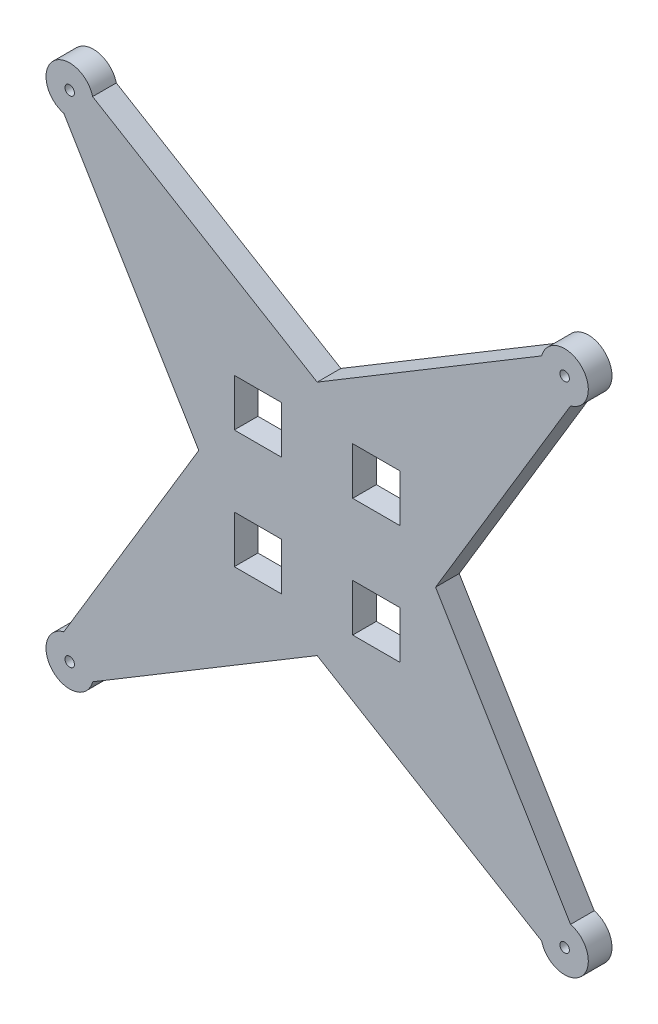
from build123d import *

# Parameters (mm, degrees)
ESBO_O1_R                = 2
ESBO_O1_W                = 20
ESBO_O1_H                = 20
RESSALTO_EXTRUS_O1_DEPTH = 10
ESBO_O3_R                = 4.5
CORTE_EXTRUS_O1_DEPTH    = 4


with BuildPart() as part:
    # Esboço1 → Ressalto-extrusão1 (new body)
    with BuildSketch(Plane.XY):
        with BuildLine():
            Line((107, 94.817541634), (50, 0))
            Line((50, 0), (107, -94.817541634))
            ThreePointArc((107, -94.817541634), (111.571067812, -111.571067812), (94.817541634, -107))
            Line((94.817541634, -107), (0, -50))
            Line((0, -50), (-94.817541634, -107))
            ThreePointArc((-94.817541634, -107), (-111.571067812, -111.571067812), (-107, -94.817541634))
            Line((-107, -94.817541634), (-50, 0))
            Line((-50, 0), (-107, 94.817541634))
            ThreePointArc((-107, 94.817541634), (-111.571067812, 111.571067812), (-94.817541634, 107))
            Line((-94.817541634, 107), (0, 50))
            Line((0, 50), (94.817541634, 107))
            ThreePointArc((94.817541634, 107), (111.571067812, 111.571067812), (107, 94.817541634))
        make_face()
        with Locations((-104.5, 104.5)):
            Circle(ESBO_O1_R, mode=Mode.SUBTRACT)
        with Locations((104.5, 104.5)):
            Circle(ESBO_O1_R, mode=Mode.SUBTRACT)
        with Locations((104.5, -104.5)):
            Circle(ESBO_O1_R, mode=Mode.SUBTRACT)
        with Locations((-104.5, -104.5)):
            Circle(ESBO_O1_R, mode=Mode.SUBTRACT)
        with Locations((25, -25)):
            Rectangle(ESBO_O1_W, ESBO_O1_H, mode=Mode.SUBTRACT)
        with Locations((25, 25)):
            Rectangle(ESBO_O1_W, ESBO_O1_H, mode=Mode.SUBTRACT)
        with Locations((-25, 25)):
            Rectangle(ESBO_O1_W, ESBO_O1_H, mode=Mode.SUBTRACT)
        with Locations((-25, -25)):
            Rectangle(ESBO_O1_W, ESBO_O1_H, mode=Mode.SUBTRACT)
    extrude(amount=RESSALTO_EXTRUS_O1_DEPTH)

    # Esboço3 → Corte-extrusão1 (cut)
    with BuildSketch(Plane(origin=(0, 0, 0), x_dir=(-1, 0, 0), z_dir=(0, 0, -1))):
        with Locations((-104.5, 104.5)):
            Circle(ESBO_O3_R)
        with Locations((104.5, 104.5)):
            Circle(ESBO_O3_R)
        with Locations((104.5, -104.5)):
            Circle(ESBO_O3_R)
        with Locations((-104.5, -104.5)):
            Circle(ESBO_O3_R)
    extrude(amount=-CORTE_EXTRUS_O1_DEPTH, mode=Mode.SUBTRACT)


solid = part.part
